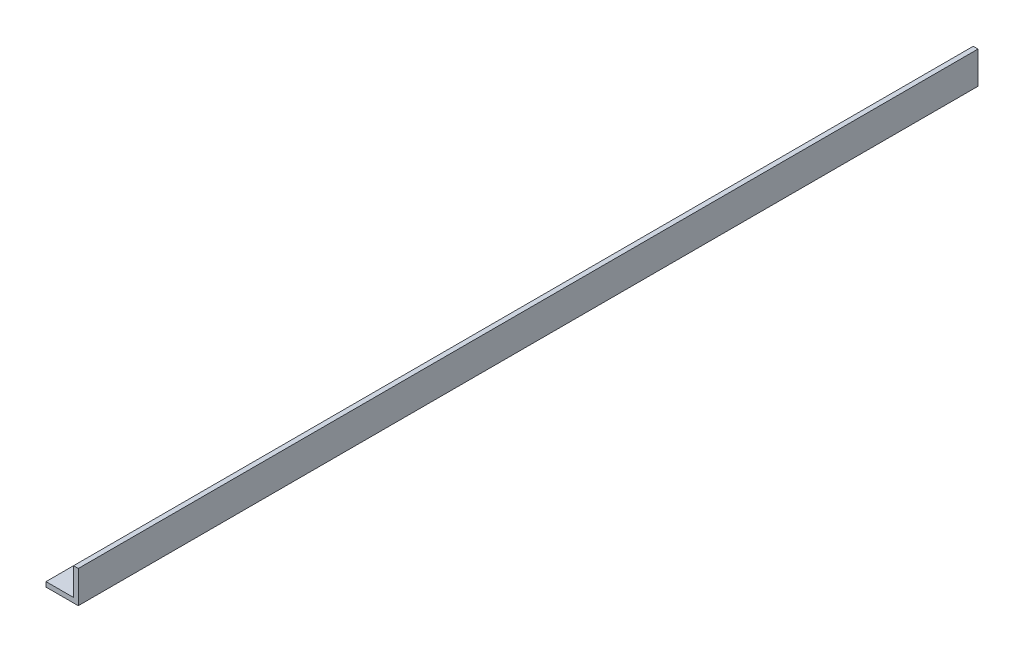
from build123d import *

# Parameters (mm, degrees)
BOSS_EXTRUDE1_DEPTH = 753


with BuildPart() as part:
    # Sketch1 → Boss-Extrude1 (new body)
    with BuildSketch(Plane.XY):
        Polygon((0, 0), (27, 0), (27, 27), (23, 27), (23, 4), (0, 4), align=None)
    extrude(amount=BOSS_EXTRUDE1_DEPTH)


solid = part.part
